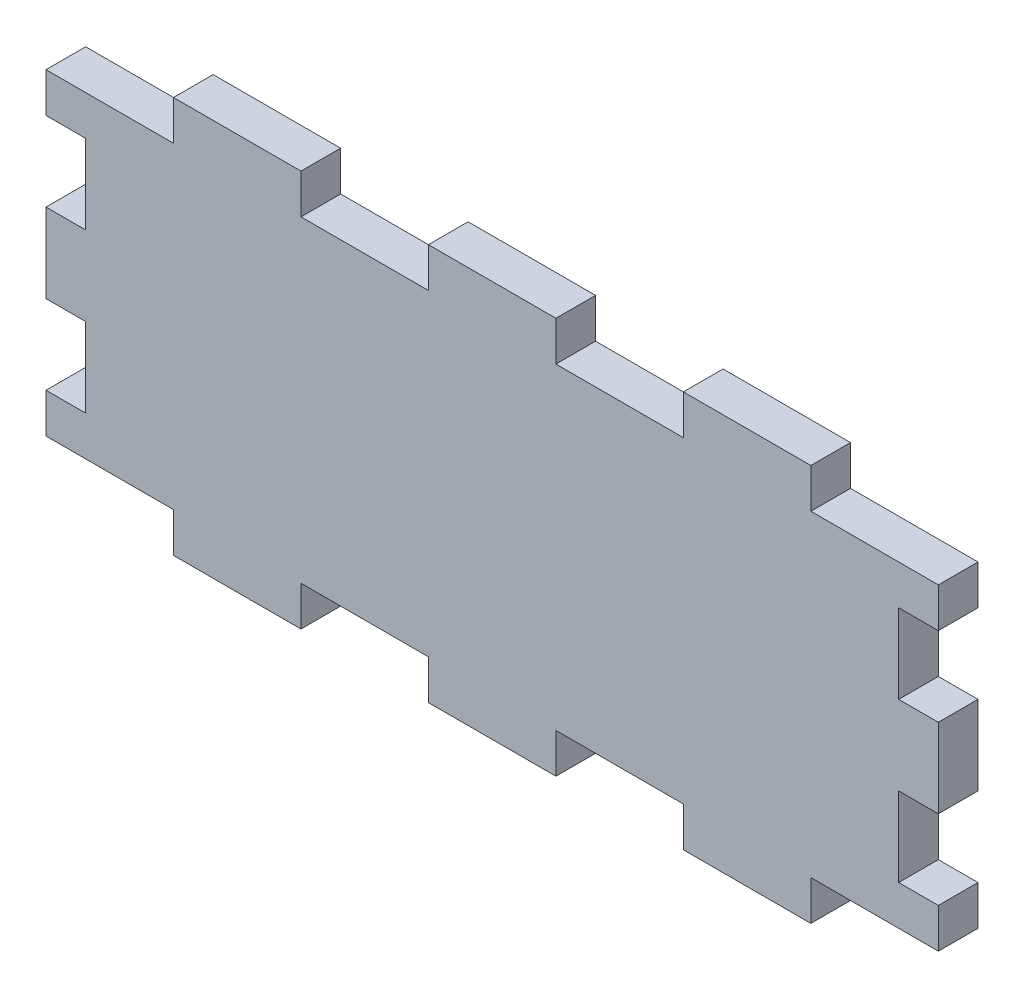
from build123d import *

# Parameters (mm, degrees)
BUITENAFMETING_RECHTHOEK_W  = 90
BUITENAFMETING_RECHTHOEK_H  = 40
PLAAT_DEPTH                 = 4
TAND_HOR_W                  = 12.857142857
TAND_HOR_H                  = 4
TAND_BOVEN_DEPTH            = 5
TANDEN_PATROON_BOVEN_COUNT  = 4
TANDEN_PATROON_BOVEN_PITCH  = 25.714285714
TAND_VER_W                  = 4
TAND_VER_H                  = 8
TAND_LINKS_DEPTH            = 5
TANDEN_PATROON_LINKS_COUNT  = 2
TANDEN_PATROON_LINKS_PITCH  = 16
TAND_O_W                    = 12.857142857
TAND_O_H                    = 4
TAND_ONDER_DEPTH            = 5
TANDEN_PATROON_ONDER_COUNT  = 4
TANDEN_PATROON_ONDER_PITCH  = 25.714285714
TAND_R_W                    = 4
TAND_R_H                    = 8
TAND_RECHTS_DEPTH           = 5
TANDEN_PATROON_RECHTS_COUNT = 2
TANDEN_PATROON_RECHTS_PITCH = 16


with BuildPart() as part:
    # Buitenafmeting Rechthoek → Plaat (new body)
    with BuildSketch(Plane.XY):
        with Locations((45, 20)):
            Rectangle(BUITENAFMETING_RECHTHOEK_W, BUITENAFMETING_RECHTHOEK_H)
    extrude(amount=-PLAAT_DEPTH)

    # Tand Hor → Tand Boven (cut, through all)
    with BuildSketch(Plane.XY):
        with Locations((6.428571429, 38)):
            Rectangle(TAND_HOR_W, TAND_HOR_H)
    tand_boven = extrude(amount=-TAND_BOVEN_DEPTH, mode=Mode.SUBTRACT)

    # Tanden Patroon Boven: Tand Boven ×4
    with Locations(*[(i * TANDEN_PATROON_BOVEN_PITCH, 0, 0) for i in range(1, TANDEN_PATROON_BOVEN_COUNT)]):
        add(tand_boven, mode=Mode.SUBTRACT)

    # Tand Ver → Tand Links (cut, through all)
    with BuildSketch(Plane.XY):
        with Locations((2, 28)):
            Rectangle(TAND_VER_W, TAND_VER_H)
    tand_links = extrude(amount=-TAND_LINKS_DEPTH, mode=Mode.SUBTRACT)

    # Tanden Patroon Links: Tand Links ×2
    with Locations(*[(0, -i * TANDEN_PATROON_LINKS_PITCH, 0) for i in range(1, TANDEN_PATROON_LINKS_COUNT)]):
        add(tand_links, mode=Mode.SUBTRACT)

    # Tand O → Tand Onder (cut, through all)
    with BuildSketch(Plane.XY):
        with Locations((6.428571429, 2)):
            Rectangle(TAND_O_W, TAND_O_H)
    tand_onder = extrude(amount=-TAND_ONDER_DEPTH, mode=Mode.SUBTRACT)

    # Tanden Patroon Onder: Tand Onder ×4
    with Locations(*[(i * TANDEN_PATROON_ONDER_PITCH, 0, 0) for i in range(1, TANDEN_PATROON_ONDER_COUNT)]):
        add(tand_onder, mode=Mode.SUBTRACT)

    # Tand R → Tand Rechts (cut, through all)
    with BuildSketch(Plane.XY):
        with Locations((88, 28)):
            Rectangle(TAND_R_W, TAND_R_H)
    tand_rechts = extrude(amount=-TAND_RECHTS_DEPTH, mode=Mode.SUBTRACT)

    # Tanden Patroon Rechts: Tand Rechts ×2
    with Locations(*[(0, -i * TANDEN_PATROON_RECHTS_PITCH, 0) for i in range(1, TANDEN_PATROON_RECHTS_COUNT)]):
        add(tand_rechts, mode=Mode.SUBTRACT)


solid = part.part
